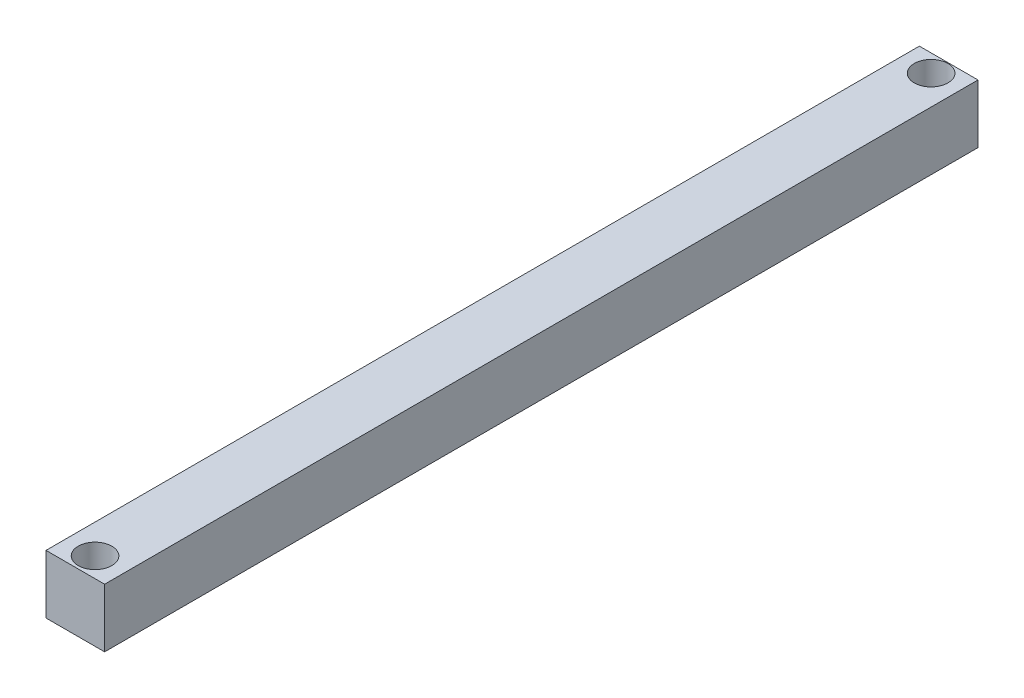
from build123d import *

# Parameters (mm, degrees)
SKETCH1_W           = 20
SKETCH1_H           = 298
BOSS_EXTRUDE1_DEPTH = 20
SKETCH3_R           = 5.75
CUT_EXTRUDE1_DEPTH  = 21


with BuildPart() as part:
    # Sketch1 → Boss-Extrude1 (new body)
    with BuildSketch(Plane(origin=(0, 0, 0), x_dir=(1, 0, 0), z_dir=(0, 1, 0))):
        Rectangle(SKETCH1_W, SKETCH1_H)
    extrude(amount=BOSS_EXTRUDE1_DEPTH)

    # Sketch3 → Cut-Extrude1 (cut, through all)
    with BuildSketch(Plane(origin=(0, 20, 0), x_dir=(1, 0, 0), z_dir=(0, 1, 0))):
        with Locations((0, 143)):
            Circle(SKETCH3_R)
        with Locations((0, -142.27)):
            Circle(SKETCH3_R)
    extrude(amount=-CUT_EXTRUDE1_DEPTH, mode=Mode.SUBTRACT)


solid = part.part
